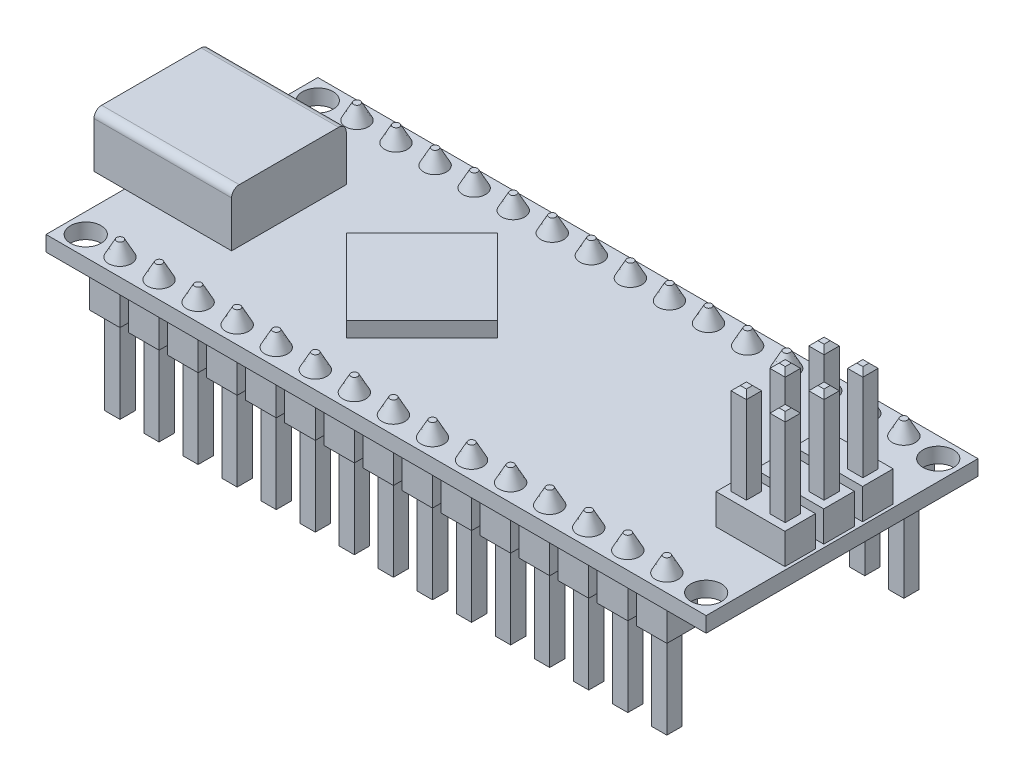
from build123d import *

# Parameters (mm, degrees)
ESBO_O1_W                           = 43.18
ESBO_O1_H                           = 17.78
RESSALTO_EXTRUS_O1_DEPTH            = 1
ESBO_O2_W                           = 2
ESBO_O2_H                           = 2
RESSALTO_EXTRUS_O2_DEPTH            = 2
ESBO_O3_W                           = 1
ESBO_O3_H                           = 1
RESSALTO_EXTRUS_O3_DEPTH            = 6
ESBO_O5_R                           = 0.75
RESSALTO_EXTRUS_O5_DEPTH            = 1
RESSALTO_EXTRUS_O5_TAPER            = 28
CHANFRO1_SIZE                       = 0.3
PADR_O_LINEAR1_COUNT                = 15
PADR_O_LINEAR1_PITCH                = 2.555
CHANFRO1_OF_PADR_O_LINEAR1_SIZE     = 0.3
RESSALTO_EXTRUS_O4_DEPTH            = 1
ESBO_O6_W                           = 9
ESBO_O6_H                           = 7.5
RESSALTO_EXTRUS_O6_DEPTH            = 3.5
ESBO_O7_R                           = 1
CORTE_EXTRUS_O1_DEPTH               = 10
ESBO_O8_W                           = 6.5
ESBO_O8_H                           = 2.5
ESBO_O8_W_2                         = 5
ESBO_O8_H_2                         = 1
CORTE_EXTRUS_O2_DEPTH               = 7
ESBO_O10_W                          = 4.5
ESBO_O10_H                          = 2
RESSALTO_EXTRUS_O7_DEPTH            = 2
ESBO_O11_W                          = 1
ESBO_O11_H                          = 1
RESSALTO_EXTRUS_O8_DEPTH            = 6
CHANFRO2_SIZE                       = 0.3
PADR_O_LINEAR2_COUNT                = 2
PADR_O_LINEAR2_PITCH                = 2.54
CHANFRO2_OF_PADR_O_LINEAR2_SIZE     = 0.3
PADR_O_LINEAR2_COL_COUNT            = 2
PADR_O_LINEAR2_COL_PITCH            = 2.54
CHANFRO2_OF_PADR_O_LINEAR2_COL_SIZE = 0.3
FILETE1_R                           = 0.5


with BuildPart() as part:
    # Esboço1 → Ressalto-extrusão1 (new body)
    with BuildSketch(Plane(origin=(0, 0, 0), x_dir=(1, 0, 0), z_dir=(0, 1, 0))):
        Rectangle(ESBO_O1_W, ESBO_O1_H)
    extrude(amount=RESSALTO_EXTRUS_O1_DEPTH)

    # Esboço2 → Ressalto-extrusão2 (add)
    with BuildSketch(Plane.XZ):
        with Locations((-17.89, 7.75)):
            Rectangle(ESBO_O2_W, ESBO_O2_H)
        with Locations((-17.89, -7.75)):
            Rectangle(ESBO_O2_W, ESBO_O2_H)
    ressalto_extrus_o2 = extrude(amount=RESSALTO_EXTRUS_O2_DEPTH)

    # Esboço3 → Ressalto-extrusão3 (add)
    with BuildSketch(Plane.XZ.offset(2)):
        with Locations((-17.89, 7.75)):
            Rectangle(ESBO_O3_W, ESBO_O3_H)
        with Locations((-17.89, -7.75)):
            Rectangle(ESBO_O3_W, ESBO_O3_H)
    ressalto_extrus_o3 = extrude(amount=RESSALTO_EXTRUS_O3_DEPTH)

    # Esboço5 → Ressalto-extrusão5 (add)
    with BuildSketch(Plane(origin=(0, 1, 0), x_dir=(1, 0, 0), z_dir=(0, 1, 0))):
        with Locations((-17.89, 7.75)):
            Circle(ESBO_O5_R)
        with Locations((-17.89, -7.75)):
            Circle(ESBO_O5_R)
    ressalto_extrus_o5 = extrude(amount=RESSALTO_EXTRUS_O5_DEPTH, taper=RESSALTO_EXTRUS_O5_TAPER)

    # Chanfro1
    chanfro1_edges = [part.edges().sort_by_distance(p)[0] for p in [
        (-17.39, -8, 7.75),
        (-17.89, -8, 8.25),
        (-18.39, -8, 7.75),
        (-17.89, -8, 7.25),
        (-17.39, -8, -7.75),
        (-17.89, -8, -7.25),
        (-18.39, -8, -7.75),
        (-17.89, -8, -8.25),
    ]]
    chamfer(chanfro1_edges, length=CHANFRO1_SIZE)

    # Padrão linear1: Ressalto-extrusão2, Ressalto-extrusão3, Ressalto-extrusão5 ×15
    with Locations(*[(i * PADR_O_LINEAR1_PITCH, 0, 0) for i in range(1, PADR_O_LINEAR1_COUNT)]):
        add(ressalto_extrus_o2)
        add(ressalto_extrus_o3)
        add(ressalto_extrus_o5)

    # Chanfro1 of Padrão linear1
    chanfro1_of_padr_o_linear1_edges = [part.edges().sort_by_distance(p)[0] for p in [
        (-14.835, -8, 7.75),
        (-15.335, -8, 8.25),
        (-15.835, -8, 7.75),
        (-15.335, -8, 7.25),
        (-14.835, -8, -7.75),
        (-15.335, -8, -7.25),
        (-15.835, -8, -7.75),
        (-15.335, -8, -8.25),
        (-12.28, -8, 7.75),
        (-12.78, -8, 8.25),
        (-13.28, -8, 7.75),
        (-12.78, -8, 7.25),
        (-12.28, -8, -7.75),
        (-12.78, -8, -7.25),
        (-13.28, -8, -7.75),
        (-12.78, -8, -8.25),
        (-9.725, -8, 7.75),
        (-10.225, -8, 8.25),
        (-10.725, -8, 7.75),
        (-10.225, -8, 7.25),
        (-9.725, -8, -7.75),
        (-10.225, -8, -7.25),
        (-10.725, -8, -7.75),
        (-10.225, -8, -8.25),
        (-7.17, -8, 7.75),
        (-7.67, -8, 8.25),
        (-8.17, -8, 7.75),
        (-7.67, -8, 7.25),
        (-7.17, -8, -7.75),
        (-7.67, -8, -7.25),
        (-8.17, -8, -7.75),
        (-7.67, -8, -8.25),
        (-4.615, -8, 7.75),
        (-5.115, -8, 8.25),
        (-5.615, -8, 7.75),
        (-5.115, -8, 7.25),
        (-4.615, -8, -7.75),
        (-5.115, -8, -7.25),
        (-5.615, -8, -7.75),
        (-5.115, -8, -8.25),
        (-2.06, -8, 7.75),
        (-2.56, -8, 8.25),
        (-3.06, -8, 7.75),
        (-2.56, -8, 7.25),
        (-2.06, -8, -7.75),
        (-2.56, -8, -7.25),
        (-3.06, -8, -7.75),
        (-2.56, -8, -8.25),
        (0.495, -8, 7.75),
        (-0.005, -8, 8.25),
        (-0.505, -8, 7.75),
        (-0.005, -8, 7.25),
        (0.495, -8, -7.75),
        (-0.005, -8, -7.25),
        (-0.505, -8, -7.75),
        (-0.005, -8, -8.25),
        (3.05, -8, 7.75),
        (2.55, -8, 8.25),
        (2.05, -8, 7.75),
        (2.55, -8, 7.25),
        (3.05, -8, -7.75),
        (2.55, -8, -7.25),
        (2.05, -8, -7.75),
        (2.55, -8, -8.25),
        (5.605, -8, 7.75),
        (5.105, -8, 8.25),
        (4.605, -8, 7.75),
        (5.105, -8, 7.25),
        (5.605, -8, -7.75),
        (5.105, -8, -7.25),
        (4.605, -8, -7.75),
        (5.105, -8, -8.25),
        (8.16, -8, 7.75),
        (7.66, -8, 8.25),
        (7.16, -8, 7.75),
        (7.66, -8, 7.25),
        (8.16, -8, -7.75),
        (7.66, -8, -7.25),
        (7.16, -8, -7.75),
        (7.66, -8, -8.25),
        (10.715, -8, 7.75),
        (10.215, -8, 8.25),
        (9.715, -8, 7.75),
        (10.215, -8, 7.25),
        (10.715, -8, -7.75),
        (10.215, -8, -7.25),
        (9.715, -8, -7.75),
        (10.215, -8, -8.25),
        (13.27, -8, 7.75),
        (12.77, -8, 8.25),
        (12.27, -8, 7.75),
        (12.77, -8, 7.25),
        (13.27, -8, -7.75),
        (12.77, -8, -7.25),
        (12.27, -8, -7.75),
        (12.77, -8, -8.25),
        (15.825, -8, 7.75),
        (15.325, -8, 8.25),
        (14.825, -8, 7.75),
        (15.325, -8, 7.25),
        (15.825, -8, -7.75),
        (15.325, -8, -7.25),
        (14.825, -8, -7.75),
        (15.325, -8, -8.25),
        (18.38, -8, 7.75),
        (17.88, -8, 8.25),
        (17.38, -8, 7.75),
        (17.88, -8, 7.25),
        (18.38, -8, -7.75),
        (17.88, -8, -7.25),
        (17.38, -8, -7.75),
        (17.88, -8, -8.25),
    ]]
    chamfer(chanfro1_of_padr_o_linear1_edges, length=CHANFRO1_OF_PADR_O_LINEAR1_SIZE)

    # Esboço4 → Ressalto-extrusão4 (add)
    with BuildSketch(Plane(origin=(0, 1, 0), x_dir=(1, 0, 0), z_dir=(0, 1, 0))):
        Polygon((-10.839747468, 0), (-5.89, 4.949747468), (-0.940252532, 0), (-5.89, -4.949747468), align=None)
    extrude(amount=RESSALTO_EXTRUS_O4_DEPTH)

    # Esboço6 → Ressalto-extrusão6 (add)
    with BuildSketch(Plane(origin=(0, 1, 0), x_dir=(1, 0, 0), z_dir=(0, 1, 0))):
        with Locations((-19.09, 0)):
            Rectangle(ESBO_O6_W, ESBO_O6_H)
    extrude(amount=RESSALTO_EXTRUS_O6_DEPTH)

    # Esboço7 → Corte-extrusão1 (cut, through all)
    with BuildSketch(Plane(origin=(0, 1, 0), x_dir=(1, 0, 0), z_dir=(0, 1, 0))):
        with Locations((-20.29, 7.59)):
            Circle(ESBO_O7_R)
        with Locations((-20.29, -7.59)):
            Circle(ESBO_O7_R)
        with Locations((20.29, -7.59)):
            Circle(ESBO_O7_R)
        with Locations((20.29, 7.59)):
            Circle(ESBO_O7_R)
    extrude(amount=-CORTE_EXTRUS_O1_DEPTH, mode=Mode.SUBTRACT)

    # Esboço8 → Corte-extrusão2 (cut)
    with BuildSketch(Plane.ZY.offset(23.59)):
        with Locations((0, 2.75)):
            Rectangle(ESBO_O8_W, ESBO_O8_H)
        with Locations((0, 2.75)):
            Rectangle(ESBO_O8_W_2, ESBO_O8_H_2, mode=Mode.SUBTRACT)
    extrude(amount=-CORTE_EXTRUS_O2_DEPTH, mode=Mode.SUBTRACT)

    # Esboço10 → Ressalto-extrusão7 (add)
    with BuildSketch(Plane(origin=(0, 1, 0), x_dir=(1, 0, 0), z_dir=(0, 1, 0))):
        with Locations((19.14, 0)):
            Rectangle(ESBO_O10_W, ESBO_O10_H)
    ressalto_extrus_o7 = extrude(amount=RESSALTO_EXTRUS_O7_DEPTH)

    # Esboço11 → Ressalto-extrusão8 (add)
    with BuildSketch(Plane(origin=(0, 3, 0), x_dir=(1, 0, 0), z_dir=(0, 1, 0))):
        with Locations((17.87, 0)):
            Rectangle(ESBO_O11_W, ESBO_O11_H)
        with Locations((20.41, 0)):
            Rectangle(ESBO_O11_W, ESBO_O11_H)
    ressalto_extrus_o8 = extrude(amount=RESSALTO_EXTRUS_O8_DEPTH)

    # Chanfro2
    chanfro2_edges = [part.edges().sort_by_distance(p)[0] for p in [
        (19.91, 9, 0),
        (20.41, 9, 0.5),
        (20.91, 9, 0),
        (20.41, 9, -0.5),
        (17.37, 9, 0),
        (17.87, 9, 0.5),
        (18.37, 9, 0),
        (17.87, 9, -0.5),
    ]]
    chamfer(chanfro2_edges, length=CHANFRO2_SIZE)

    # Padrão linear2: Ressalto-extrusão7, Ressalto-extrusão8 ×2
    with Locations(*[(0, 0, i * PADR_O_LINEAR2_PITCH) for i in range(1, PADR_O_LINEAR2_COUNT)]):
        add(ressalto_extrus_o7)
        add(ressalto_extrus_o8)

    # Chanfro2 of Padrão linear2
    chanfro2_of_padr_o_linear2_edges = [part.edges().sort_by_distance(p)[0] for p in [
        (19.91, 9, 2.54),
        (20.41, 9, 3.04),
        (20.91, 9, 2.54),
        (20.41, 9, 2.04),
        (17.37, 9, 2.54),
        (17.87, 9, 3.04),
        (18.37, 9, 2.54),
        (17.87, 9, 2.04),
    ]]
    chamfer(chanfro2_of_padr_o_linear2_edges, length=CHANFRO2_OF_PADR_O_LINEAR2_SIZE)

    # Padrão linear2 col: Ressalto-extrusão7, Ressalto-extrusão8 ×2
    with Locations(*[(0, 0, -i * PADR_O_LINEAR2_COL_PITCH) for i in range(1, PADR_O_LINEAR2_COL_COUNT)]):
        add(ressalto_extrus_o7)
        add(ressalto_extrus_o8)

    # Chanfro2 of Padrão linear2 col
    chanfro2_of_padr_o_linear2_col_edges = [part.edges().sort_by_distance(p)[0] for p in [
        (19.91, 9, -2.54),
        (20.41, 9, -2.04),
        (20.91, 9, -2.54),
        (20.41, 9, -3.04),
        (17.37, 9, -2.54),
        (17.87, 9, -2.04),
        (18.37, 9, -2.54),
        (17.87, 9, -3.04),
    ]]
    chamfer(chanfro2_of_padr_o_linear2_col_edges, length=CHANFRO2_OF_PADR_O_LINEAR2_COL_SIZE)

    # Filete1
    filete1_edges = [part.edges().sort_by_distance(p)[0] for p in [
        (-19.09, 4.5, -3.75),
        (-19.09, 4.5, 3.75),
    ]]
    fillet(filete1_edges, radius=FILETE1_R)


solid = part.part
